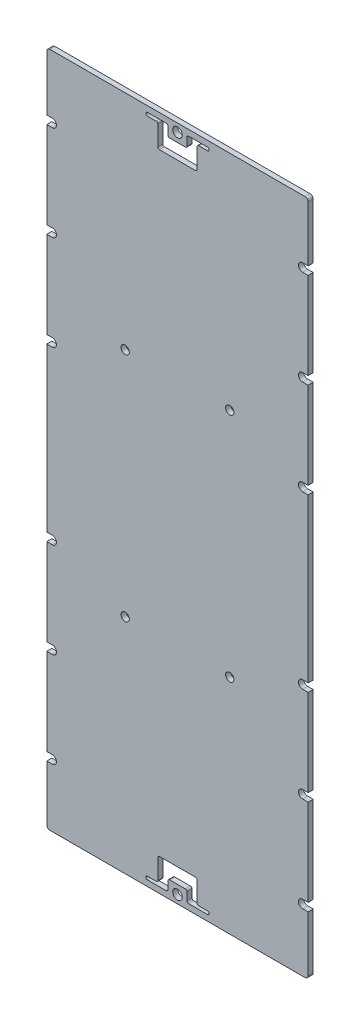
from build123d import *

# Parameters (mm, degrees)
SKETCH1_W                  = 82.8
SKETCH1_H                  = 213.8
SKETCH1_R                  = 0.8
PCB_EXTRUDE_DEPTH          = 1.6
SKETCH7_W                  = 82.5
SKETCH7_H                  = 213.5
OFFSET_EDGES_DEPTH         = 1.6
CORNER_FILLETS_ON_PCB_R    = 1
SKETCH3_R                  = 1.5
SOLAR_HOLE_DEPTH           = 1.6
FILLETS_FOR_SOLAR_HOLE_R   = 0.5
M2_CLEARANCE_HOLE1_D       = 2.6
SKETCH6_W                  = 1.75
SKETCH6_H                  = 2.6
SLOTS_FOR_EDGE_HOLES_DEPTH = 1.6


with BuildPart() as part:
    # Sketch1 → pcb extrude (new body)
    with BuildSketch(Plane.XY):
        Rectangle(SKETCH1_W, SKETCH1_H)
        with Locations((-39.5, -27)):
            Circle(SKETCH1_R, mode=Mode.SUBTRACT)
        with Locations((39.5, -27)):
            Circle(SKETCH1_R, mode=Mode.SUBTRACT)
        with Locations((-39.5, 87)):
            Circle(SKETCH1_R, mode=Mode.SUBTRACT)
        with Locations((-39.5, 57)):
            Circle(SKETCH1_R, mode=Mode.SUBTRACT)
        with Locations((-39.5, 27)):
            Circle(SKETCH1_R, mode=Mode.SUBTRACT)
        with Locations((-16.5, 36.5)):
            Circle(SKETCH1_R, mode=Mode.SUBTRACT)
        with Locations((-16.5, -36.5)):
            Circle(SKETCH1_R, mode=Mode.SUBTRACT)
        with Locations((-39.5, -57)):
            Circle(SKETCH1_R, mode=Mode.SUBTRACT)
        with Locations((-39.5, -87)):
            Circle(SKETCH1_R, mode=Mode.SUBTRACT)
        with Locations((0, -104.2)):
            Circle(SKETCH1_R, mode=Mode.SUBTRACT)
        with Locations((39.5, -87)):
            Circle(SKETCH1_R, mode=Mode.SUBTRACT)
        with Locations((39.5, -57)):
            Circle(SKETCH1_R, mode=Mode.SUBTRACT)
        with Locations((16.5, -36.5)):
            Circle(SKETCH1_R, mode=Mode.SUBTRACT)
        with Locations((39.5, 27)):
            Circle(SKETCH1_R, mode=Mode.SUBTRACT)
        with Locations((16.5, 36.5)):
            Circle(SKETCH1_R, mode=Mode.SUBTRACT)
        with Locations((39.5, 57)):
            Circle(SKETCH1_R, mode=Mode.SUBTRACT)
        with Locations((39.5, 87)):
            Circle(SKETCH1_R, mode=Mode.SUBTRACT)
        with Locations((0, 104.2)):
            Circle(SKETCH1_R, mode=Mode.SUBTRACT)
    extrude(amount=PCB_EXTRUDE_DEPTH)

    # Sketch7 → Offset Edges (cut)
    with BuildSketch(Plane.XY.offset(1.6)):
        Polygon((-41.25, 106.9), (-41.4, 106.9), (-41.4, -106.9), (-41.25, -106.9), (41.25, -106.9), (41.4, -106.9), (41.4, 106.9), (41.25, 106.9), align=None)
        Rectangle(SKETCH7_W, SKETCH7_H, mode=Mode.SUBTRACT)
    extrude(amount=-OFFSET_EDGES_DEPTH, mode=Mode.SUBTRACT)

    # corner fillets on PCB
    corner_fillets_on_pcb_edges = [part.edges().sort_by_distance(p)[0] for p in [
        (41.25, -106.75, 0.8),
        (41.25, 106.75, 0.8),
        (-41.25, 106.75, 0.8),
        (-41.25, -106.75, 0.8),
    ]]
    fillet(corner_fillets_on_pcb_edges, radius=CORNER_FILLETS_ON_PCB_R)

    # Sketch3 → Solar Hole (cut)
    with BuildSketch(Plane.XY.offset(1.6)):
        with Locations((0, 104.2)):
            Circle(SKETCH3_R)
        with BuildLine():
            Line((-3, 101.4), (3, 101.4))
            Line((3, 101.4), (3, 104.9))
            Line((3, 104.9), (9.5, 104.9))
            ThreePointArc((9.5, 104.9), (10, 104.4), (9.5, 103.9))
            Line((9.5, 103.9), (6.2, 103.9))
            Line((6.2, 103.9), (6.2, 96.6))
            Line((6.2, 96.6), (-6.2, 96.6))
            Line((-6.2, 96.6), (-6.2, 103.9))
            Line((-6.2, 103.9), (-9.5, 103.9))
            ThreePointArc((-9.5, 103.9), (-10, 104.4), (-9.5, 104.9))
            Line((-9.5, 104.9), (-3, 104.9))
            Line((-3, 104.9), (-3, 101.4))
        make_face()
    solar_hole = extrude(amount=-SOLAR_HOLE_DEPTH, mode=Mode.SUBTRACT)

    # Mirror solar hole: Solar Hole across plane
    add(solar_hole.mirror(Plane.ZX), mode=Mode.SUBTRACT)

    # fillets for solar hole
    fillets_for_solar_hole_edges = [part.edges().sort_by_distance(p)[0] for p in [
        (6.2, 103.9, 0.8),
        (6.2, 96.6, 0.8),
        (-6.2, 96.6, 0.8),
        (-6.2, 103.9, 0.8),
        (-3, 104.9, 0.8),
        (-3, 101.4, 0.8),
        (3, 101.4, 0.8),
        (3, 104.9, 0.8),
        (6.2, -103.9, 0.8),
        (6.2, -96.6, 0.8),
        (-6.2, -96.6, 0.8),
        (-6.2, -103.9, 0.8),
        (-3, -104.9, 0.8),
        (-3, -101.4, 0.8),
        (3, -101.4, 0.8),
        (3, -104.9, 0.8),
    ]]
    fillet(fillets_for_solar_hole_edges, radius=FILLETS_FOR_SOLAR_HOLE_R)

    # M2 Clearance Hole1 (through all)
    with Locations(Plane(origin=(0, 0, 0), x_dir=(-1, 0, 0), z_dir=(0, 0, -1))):
        with Locations((39.5, 87), (-39.5, 87), (16.5, 36.5), (-16.5, 36.5), (39.5, 57), (-39.5, 57), (39.5, 27), (-39.5, 27), (39.5, -57), (16.5, -36.5), (-16.5, -36.5), (-39.5, -57), (-39.5, -87), (39.5, -87), (39.5, -27), (-39.5, -27)):
            Hole(M2_CLEARANCE_HOLE1_D / 2)

    # Sketch6 → slots for edge holes (cut)
    with BuildSketch(Plane.XY.offset(1.6)):
        with Locations((-40.375, 87)):
            Rectangle(SKETCH6_W, SKETCH6_H)
        with Locations((40.375, 87)):
            Rectangle(SKETCH6_W, SKETCH6_H)
        with Locations((40.375, 57)):
            Rectangle(SKETCH6_W, SKETCH6_H)
        with Locations((40.375, 27)):
            Rectangle(SKETCH6_W, SKETCH6_H)
        with Locations((-40.375, 57)):
            Rectangle(SKETCH6_W, SKETCH6_H)
        with Locations((-40.375, 27)):
            Rectangle(SKETCH6_W, SKETCH6_H)
        with Locations((40.375, -87)):
            Rectangle(SKETCH6_W, SKETCH6_H)
        with Locations((-40.375, -87)):
            Rectangle(SKETCH6_W, SKETCH6_H)
        with Locations((40.375, -57)):
            Rectangle(SKETCH6_W, SKETCH6_H)
        with Locations((40.375, -27)):
            Rectangle(SKETCH6_W, SKETCH6_H)
        with Locations((-40.375, -57)):
            Rectangle(SKETCH6_W, SKETCH6_H)
        with Locations((-40.375, -27)):
            Rectangle(SKETCH6_W, SKETCH6_H)
    extrude(amount=-SLOTS_FOR_EDGE_HOLES_DEPTH, mode=Mode.SUBTRACT)


solid = part.part
